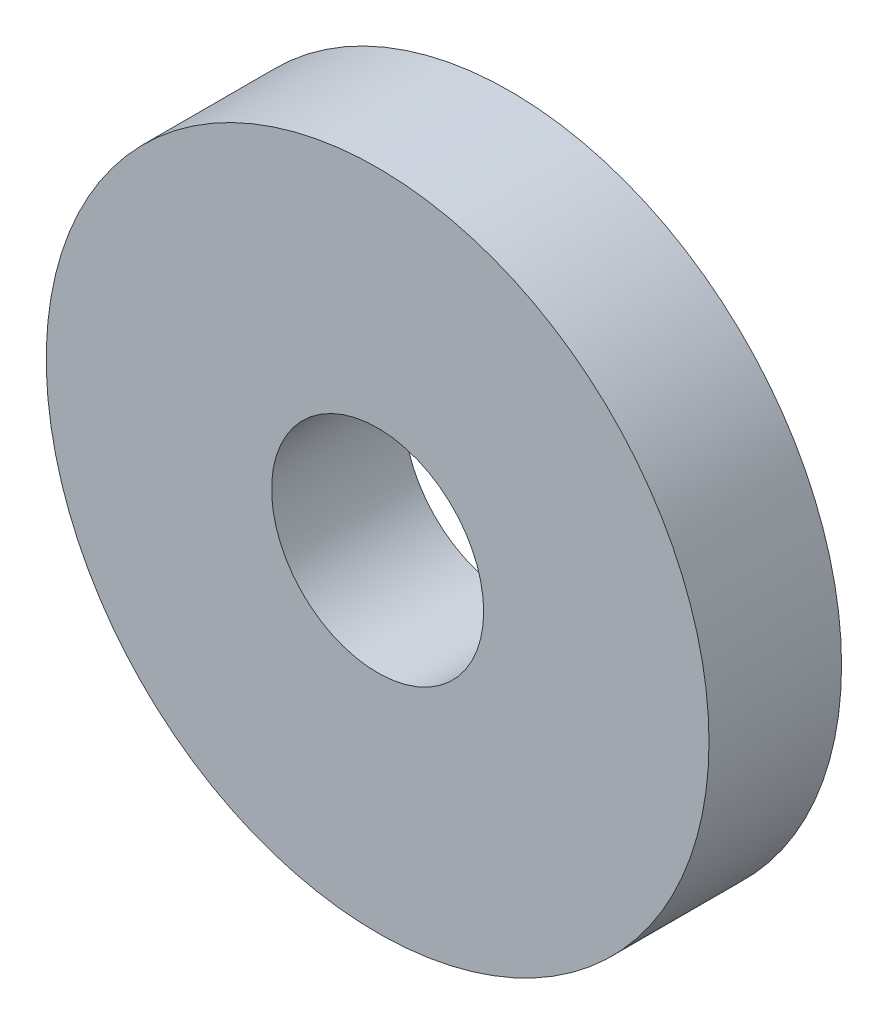
from build123d import *

# Parameters (mm, degrees)
SKETCH_1_R      = 5
SKETCH_1_R_2    = 1.6
EXTRUDE_1_DEPTH = 2


with BuildPart() as part:
    # 草图1 → 凸台-拉伸1 (new body)
    with BuildSketch(Plane.XY):
        Circle(SKETCH_1_R)
        Circle(SKETCH_1_R_2, mode=Mode.SUBTRACT)
    extrude(amount=EXTRUDE_1_DEPTH)


solid = part.part
